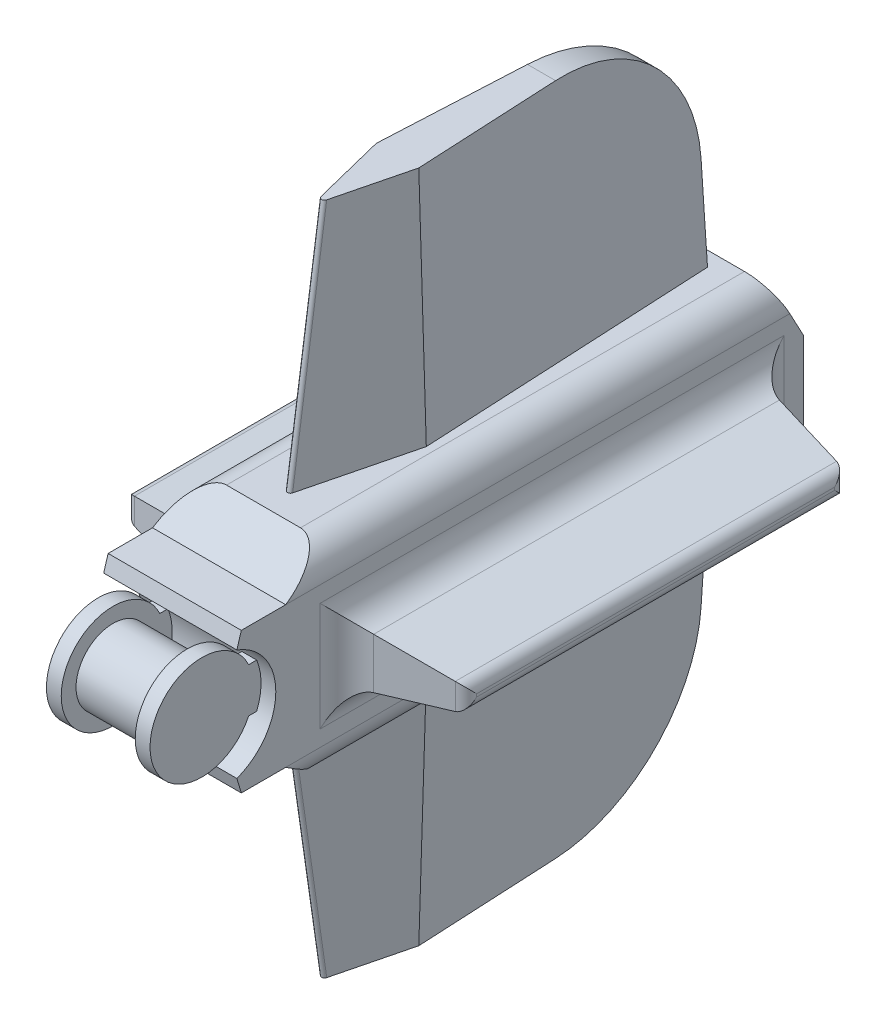
from build123d import *

# Parameters (mm, degrees)
SKETCH1_R                = 3.175
BOSS_EXTRUDE1_DEPTH      = 3.175
SKETCH2_R                = 4.445
BOSS_EXTRUDE2_DEPTH      = 1.27
SKETCH3_W                = 6.35
SKETCH3_H                = 3.81
BOSS_EXTRUDE3_DEPTH      = 1.27
BOSS_EXTRUDE4_DEPTH      = 8.89
BOSS_EXTRUDE4_DEPTH_BACK = 2.54
SKETCH5_R                = 3.175
CUT_EXTRUDE1_DEPTH       = 12.7
FILLET1_R                = 2.54
SKETCH6_W                = 35.56
SKETCH6_H                = 5.08
BOSS_EXTRUDE5_DEPTH      = 8.89
BOSS_EXTRUDE5_TAPER      = 10
FILLET2_R                = 1.016
FILLET3_R                = 2.54
BOSS_EXTRUDE6_DEPTH      = 20.32
BOSS_EXTRUDE6_TAPER      = 2
FILLET4_R                = 0.254
FILLET5_R                = 12.7


with BuildPart() as part:
    # Sketch1 → Boss-Extrude1 (new body, symmetric)
    with BuildSketch(Plane(origin=(0, 0, 0), x_dir=(0, 0, -1), z_dir=(1, 0, 0))):
        Circle(SKETCH1_R)
    extrude(amount=BOSS_EXTRUDE1_DEPTH, both=True)

    # Sketch2 → Boss-Extrude2 (add)
    with BuildSketch(Plane(origin=(3.175, 0, 0), x_dir=(0, 0, -1), z_dir=(1, 0, 0))):
        Circle(SKETCH2_R)
    boss_extrude2 = extrude(amount=BOSS_EXTRUDE2_DEPTH)

    # Mirror1: Boss-Extrude2 across plane
    add(boss_extrude2.mirror(Plane(origin=(0, 0, 0), x_dir=(0, 0, 1), z_dir=(1, 0, 0))))

    # Sketch3 → Boss-Extrude3 (add)
    with BuildSketch(Plane(origin=(4.445, 0, 0), x_dir=(0, 0, -1), z_dir=(1, 0, 0))):
        with Locations((3.175, 0)):
            Rectangle(SKETCH3_W, SKETCH3_H)
    boss_extrude3 = extrude(amount=-BOSS_EXTRUDE3_DEPTH)

    # Mirror2: Boss-Extrude3 across plane
    add(boss_extrude3.mirror(Plane(origin=(0, 0, 0), x_dir=(0, 0, 1), z_dir=(1, 0, 0))))

    # Sketch4 → Boss-Extrude4 (add, two sides)
    with BuildSketch(Plane(origin=(-3.175, 0, 0), x_dir=(0, 0, -1), z_dir=(1, 0, 0))) as boss_extrude4_sk:
        with BuildLine():
            Line((1.737462328, 4.773638514), (2.118462328, 6.043638514))
            Line((2.118462328, 6.043638514), (5.928462328, 6.043638514))
            Line((5.928462328, 6.043638514), (9.738462328, 8.583638514))
            Line((9.738462328, 8.583638514), (47.838462328, 8.583638514))
            Line((47.838462328, 8.583638514), (50.378462328, 3.81))
            Line((50.378462328, 3.81), (50.378462328, -3.81))
            Line((50.378462328, -3.81), (47.838462328, -8.583638514))
            Line((47.838462328, -8.583638514), (9.738462328, -8.583638514))
            Line((9.738462328, -8.583638514), (5.928462328, -6.043638514))
            Line((5.928462328, -6.043638514), (2.118462328, -6.043638514))
            Line((2.118462328, -6.043638514), (1.737462328, -4.773638514))
            ThreePointArc((1.737462328, -4.773638514), (5.08, 0), (1.737462328, 4.773638514))
        make_face()
    extrude(amount=BOSS_EXTRUDE4_DEPTH)
    extrude(boss_extrude4_sk.sketch, amount=-BOSS_EXTRUDE4_DEPTH_BACK)

    # Sketch5 → Cut-Extrude1 (cut)
    with BuildSketch(Plane(origin=(0, 0, -50.378462328), x_dir=(-1, 0, 0), z_dir=(0, 0, -1))):
        Circle(SKETCH5_R)
    extrude(amount=-CUT_EXTRUDE1_DEPTH, mode=Mode.SUBTRACT)

    # Fillet1
    fillet1_edges = [part.edges().sort_by_distance(p)[0] for p in [
        (5.715, -8.583638514, -28.788462328),
        (-5.715, -8.583638514, -28.788462328),
        (-5.715, 8.583638514, -28.788462328),
        (5.715, 8.583638514, -28.788462328),
    ]]
    fillet(fillet1_edges, radius=FILLET1_R)

    # Sketch6 → Boss-Extrude5 (add)
    with BuildSketch(Plane(origin=(5.715, 0, 0), x_dir=(0, 0, -1), z_dir=(1, 0, 0))):
        with Locations((28.788462328, 0)):
            Rectangle(SKETCH6_W, SKETCH6_H)
    boss_extrude5 = extrude(amount=BOSS_EXTRUDE5_DEPTH, taper=BOSS_EXTRUDE5_TAPER)

    # Mirror3: Boss-Extrude5 across plane
    add(boss_extrude5.mirror(Plane(origin=(0, 0, 0), x_dir=(0, 0, 1), z_dir=(1, 0, 0))))

    # Fillet2
    fillet2_edges = [part.edges().sort_by_distance(p)[0] for p in [
        (14.605, 0, -12.576009187),
        (14.605, -0.972453142, -28.788462328),
        (14.605, 0, -45.00091547),
        (14.605, 0.972453142, -28.788462328),
        (-14.605, 0, -12.576009187),
        (-14.605, 0.972453142, -28.788462328),
        (-14.605, 0, -45.00091547),
        (-14.605, -0.972453142, -28.788462328),
    ]]
    fillet(fillet2_edges, radius=FILLET2_R)

    # Fillet3
    fillet3_edges = [part.edges().sort_by_distance(p)[0] for p in [
        (5.715, 0, -11.008462328),
        (5.715, -2.54, -28.788462328),
        (5.715, 0, -46.568462328),
        (5.715, 2.54, -28.788462328),
        (-5.715, 0, -11.008462328),
        (-5.715, -2.54, -28.788462328),
        (-5.715, 0, -46.568462328),
        (-5.715, 2.54, -28.788462328),
    ]]
    fillet(fillet3_edges, radius=FILLET3_R)

    # Sketch7 → Boss-Extrude6 (add)
    with BuildSketch(Plane(origin=(0, 8.583638514, 0), x_dir=(1, 0, 0), z_dir=(0, 1, 0))):
        Polygon((-1.27, 46.568462328), (-2.54, 21.168462328), (0, 11.008462328), (2.54, 21.168462328), (1.27, 46.568462328), align=None)
    boss_extrude6 = extrude(amount=BOSS_EXTRUDE6_DEPTH, taper=BOSS_EXTRUDE6_TAPER)

    # Mirror4: Boss-Extrude6 across plane
    add(boss_extrude6.mirror(Plane.ZX))

    # Fillet4
    fillet4_edges = [part.edges().sort_by_distance(p)[0] for p in [
        (0, 18.743638514, -12.471319663),
        (0, -18.743638514, -12.471319663),
    ]]
    fillet(fillet4_edges, radius=FILLET4_R)

    # Fillet5
    fillet5_edges = [part.edges().sort_by_distance(p)[0] for p in [
        (0, 28.903638514, -45.858872292),
        (0, -28.903638514, -45.858872292),
    ]]
    fillet(fillet5_edges, radius=FILLET5_R)


solid = part.part
